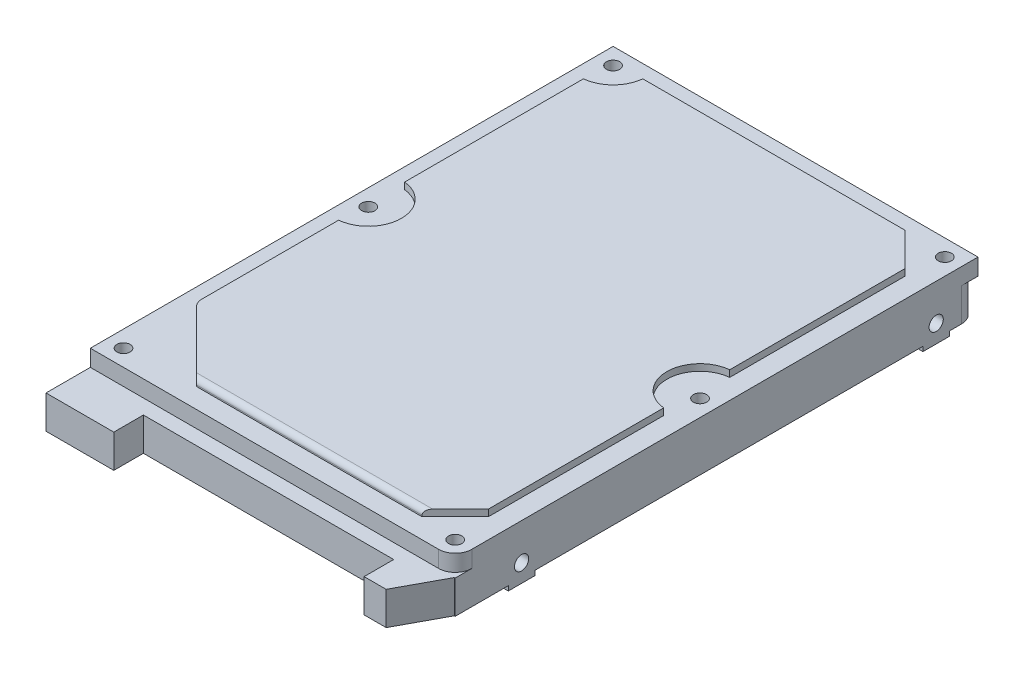
from build123d import *

# Parameters (mm, degrees)
S2D0001_W           = 69.85
S2D0001_H           = 100.076
BOSS_EXTRUDE1_DEPTH = 3.175
FILLET1_R           = 3.175
S2D0002_R           = 1.27
CUT_EXTRUDE1_DEPTH  = 3.4925
BOSS_EXTRUDE2_DEPTH = 1.27
FILLET2_R           = 2.54
FILLET3_R           = 1.016
BOSS_EXTRUDE3_DEPTH = 6.35
S2D0005_W           = 5.08
S2D0005_H           = 6.35
BOSS_EXTRUDE4_DEPTH = 69.85
BOSS_EXTRUDE5_DEPTH = 0.889
BOSS_EXTRUDE6_DEPTH = 6.35


with BuildPart() as part:
    # S2D0001 → Boss-Extrude1 (new body)
    with BuildSketch(Plane(origin=(0, 0, 0), x_dir=(1, 0, 0), z_dir=(0, 1, 0))):
        with Locations((34.925, 50.038)):
            Rectangle(S2D0001_W, S2D0001_H)
    extrude(amount=-BOSS_EXTRUDE1_DEPTH)

    # Fillet1
    fillet1_edges = [part.edges().sort_by_distance(p)[0] for p in [
        (69.85, -1.5875, 0),
    ]]
    fillet(fillet1_edges, radius=FILLET1_R)

    # S2D0002 → Cut-Extrude1 (cut)
    with BuildSketch(Plane(origin=(0, 0, 0), x_dir=(1, 0, 0), z_dir=(0, 1, 0))):
        with Locations((3.175, 96.901)):
            Circle(S2D0002_R)
        with Locations((66.675, 96.901)):
            Circle(S2D0002_R)
        with Locations((3.175, 50.038)):
            Circle(S2D0002_R)
        with Locations((66.675, 50.038)):
            Circle(S2D0002_R)
        with Locations((3.175, 3.175)):
            Circle(S2D0002_R)
        with Locations((66.675, 3.175)):
            Circle(S2D0002_R)
    extrude(amount=-CUT_EXTRUDE1_DEPTH, mode=Mode.SUBTRACT)

    # Sketch3 → Boss-Extrude2 (add)
    with BuildSketch(Plane(origin=(0, 0, 0), x_dir=(-1, 0, 0), z_dir=(0, 1, 0))):
        with BuildLine():
            Line((-9.493170226, -96.266), (-59.69, -96.266))
            Line((-59.69, -96.266), (-66.04, -89.916))
            Line((-66.04, -89.916), (-66.04, -56.356170226))
            ThreePointArc((-66.04, -56.356170226), (-60.325, -50.038), (-66.04, -43.719829774))
            Line((-66.04, -43.719829774), (-66.04, -10.16))
            Line((-66.04, -10.16), (-59.69, -3.81))
            Line((-59.69, -3.81), (-16.51, -3.81))
            Line((-16.51, -3.81), (-3.81, -16.51))
            Line((-3.81, -16.51), (-3.81, -43.719829774))
            ThreePointArc((-3.81, -43.719829774), (-9.525, -50.038), (-3.81, -56.356170226))
            Line((-3.81, -56.356170226), (-3.81, -90.582829774))
            ThreePointArc((-3.81, -90.582829774), (-7.665128061, -92.410871939), (-9.493170226, -96.266))
        make_face()
    extrude(amount=BOSS_EXTRUDE2_DEPTH)

    # Fillet2
    fillet2_edges = [part.edges().sort_by_distance(p)[0] for p in [
        (3.81, 0.635, -16.51),
    ]]
    fillet(fillet2_edges, radius=FILLET2_R)

    # Fillet3
    fillet3_edges = [part.edges().sort_by_distance(p)[0] for p in [
        (38.1, 1.27, -3.81),
    ]]
    fillet(fillet3_edges, radius=FILLET3_R)

    # Sketch4 → Boss-Extrude3 (add)
    with BuildSketch(Plane.XZ.offset(3.175)):
        with BuildLine():
            Line((0, -96.901), (0, 0))
            Line((0, 0), (69.85, 0))
            Line((69.85, 0), (69.85, -96.901))
            ThreePointArc((69.85, -96.901), (68.92006403, -99.14606403), (66.675, -100.076))
            Line((66.675, -100.076), (3.175, -100.076))
            ThreePointArc((3.175, -100.076), (0.92993597, -99.14606403), (0, -96.901))
        make_face()
    extrude(amount=BOSS_EXTRUDE3_DEPTH)

    # S2D0005 → Boss-Extrude4 (add)
    with BuildSketch(Plane(origin=(0, 0, 0), x_dir=(0, 0, -1), z_dir=(1, 0, 0))):
        with Locations((12.7, -6.35)):
            Rectangle(S2D0005_W, S2D0005_H)
        with Locations((92.075, -6.35)):
            Rectangle(S2D0005_W, S2D0005_H)
    extrude(amount=BOSS_EXTRUDE4_DEPTH)

    # S2D0007 one side → Cut-Revolve1 (revolve, cut)
    with BuildSketch(Plane(origin=(12.7, -5.6261, -92.075), x_dir=(0, 1, 0), z_dir=(0, 0, 1))):
        Polygon((-2.7178, 0), (-1.3589, -0.816509495), (-1.3589, 12.7), (-2.7178, 12.7), align=None)
    revolve(axis=Axis((14.19233497, -6.985, -92.075), (-1, 0, 0)), mode=Mode.SUBTRACT)

    # Sketch7 one side → Cut-Revolve2 (revolve, cut)
    with BuildSketch(Plane(origin=(12.7, -5.6261, -12.7), x_dir=(0, 1, 0), z_dir=(0, 0, 1))):
        Polygon((-2.7178, 0), (-1.3589, -0.816509495), (-1.3589, 12.7), (-2.7178, 12.7), align=None)
    revolve(axis=Axis((14.19233497, -6.985, -12.7), (-1, 0, 0)), mode=Mode.SUBTRACT)

    # S2D0008 one side → Cut-Revolve3 (revolve, cut)
    with BuildSketch(Plane(origin=(57.15, -8.3439, -12.7), x_dir=(0, -1, 0), z_dir=(0, 0, 1))):
        Polygon((-2.7178, 0), (-1.3589, -0.816509495), (-1.3589, 12.7), (-2.7178, 12.7), align=None)
    revolve(axis=Axis((55.65766503, -6.985, -12.7), (1, 0, 0)), mode=Mode.SUBTRACT)

    # S2D0009 one side → Cut-Revolve4 (revolve, cut)
    with BuildSketch(Plane(origin=(57.15, -8.3439, -92.075), x_dir=(0, -1, 0), z_dir=(0, 0, 1))):
        Polygon((-2.7178, 0), (-1.3589, -0.816509495), (-1.3589, 12.7), (-2.7178, 12.7), align=None)
    revolve(axis=Axis((55.65766503, -6.985, -92.075), (1, 0, 0)), mode=Mode.SUBTRACT)

    # Sketch10 → Boss-Extrude5 (add)
    with BuildSketch(Plane.XZ.offset(9.525)):
        with BuildLine():
            Line((0, -94.615), (0, -89.535))
            Line((0, -89.535), (6.35, -89.535))
            ThreePointArc((6.35, -89.535), (8.89, -92.075), (6.35, -94.615))
            Line((6.35, -94.615), (0, -94.615))
        make_face()
        with BuildLine():
            Line((0, -15.24), (0, -10.16))
            Line((0, -10.16), (6.35, -10.16))
            ThreePointArc((6.35, -10.16), (8.89, -12.7), (6.35, -15.24))
            Line((6.35, -15.24), (0, -15.24))
        make_face()
        with BuildLine():
            Line((69.85, -10.16), (69.85, -15.24))
            Line((69.85, -15.24), (63.5, -15.24))
            ThreePointArc((63.5, -15.24), (60.96, -12.7), (63.5, -10.16))
            Line((63.5, -10.16), (69.85, -10.16))
        make_face()
        with BuildLine():
            Line((69.85, -89.535), (69.85, -94.615))
            Line((69.85, -94.615), (63.5, -94.615))
            ThreePointArc((63.5, -94.615), (60.96, -92.075), (63.5, -89.535))
            Line((63.5, -89.535), (69.85, -89.535))
        make_face()
    extrude(amount=BOSS_EXTRUDE5_DEPTH)

    # S2D0019 one side → Cut-Revolve5 (revolve, cut)
    with BuildSketch(Plane(origin=(4.9911, -4.064, -92.075), x_dir=(-1, 0, 0), z_dir=(0, 0, 1))):
        Polygon((-2.7178, 0), (-1.3589, -0.816509495), (-1.3589, 6.35), (-2.7178, 6.35), align=None)
    revolve(axis=Axis((6.35, -2.88916503, -92.075), (0, -1, 0)), mode=Mode.SUBTRACT)

    # Sketch12 one side → Cut-Revolve6 (revolve, cut)
    with BuildSketch(Plane(origin=(62.1411, -4.064, -92.075), x_dir=(-1, 0, 0), z_dir=(0, 0, 1))):
        Polygon((-2.7178, 0), (-1.3589, -0.816509495), (-1.3589, 6.35), (-2.7178, 6.35), align=None)
    revolve(axis=Axis((63.5, -2.88916503, -92.075), (0, -1, 0)), mode=Mode.SUBTRACT)

    # S2D0021 one side → Cut-Revolve7 (revolve, cut)
    with BuildSketch(Plane(origin=(62.1411, -4.064, -12.7), x_dir=(-1, 0, 0), z_dir=(0, 0, 1))):
        Polygon((-2.7178, 0), (-1.3589, -0.816509495), (-1.3589, 6.35), (-2.7178, 6.35), align=None)
    revolve(axis=Axis((63.5, -2.88916503, -12.7), (0, -1, 0)), mode=Mode.SUBTRACT)

    # Sketch14 one side → Cut-Revolve8 (revolve, cut)
    with BuildSketch(Plane(origin=(4.9911, -4.064, -12.7), x_dir=(-1, 0, 0), z_dir=(0, 0, 1))):
        Polygon((-2.7178, 0), (-1.3589, -0.816509495), (-1.3589, 6.35), (-2.7178, 6.35), align=None)
    revolve(axis=Axis((6.35, -2.88916503, -12.7), (0, -1, 0)), mode=Mode.SUBTRACT)

    # Sketch15 → Boss-Extrude6 (add)
    with BuildSketch(Plane.XZ.offset(9.525)):
        Polygon((69.683605301, 0), (65.111605301, 8.4836), (60.895205301, 8.4836), (60.895205301, 2.8194), (12.9794, 2.8194), (12.9794, 8.4836), (0, 8.4836), (0, 0), align=None)
    extrude(amount=-BOSS_EXTRUDE6_DEPTH)


solid = part.part
